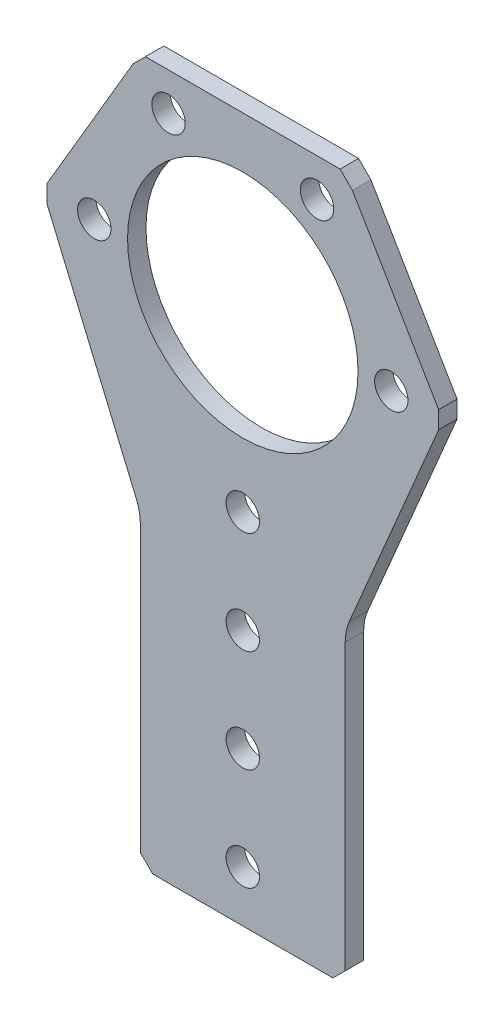
from build123d import *

# Parameters (mm, degrees)
SKETCH1_R           = 2.0701
SKETCH1_R_2         = 14.2875
BOSS_EXTRUDE1_DEPTH = 2.286


with BuildPart() as part:
    # Sketch1 → Boss-Extrude1 (new body)
    with BuildSketch(Plane.XY.offset(2.286)):
        with BuildLine():
            Line((-24.282138093, -1.253612903), (-13.20363246, -27.386969147))
            ThreePointArc((-13.20363246, -27.386969147), (-12.827181753, -28.600844397), (-12.7, -29.865373188))
            Line((-12.7, -29.865373188), (-12.7, -65.148356459))
            Line((-12.7, -65.148356459), (-11.173356459, -66.675))
            Line((-11.173356459, -66.675), (11.173356459, -66.675))
            Line((11.173356459, -66.675), (12.7, -65.148356459))
            Line((12.7, -65.148356459), (12.7, -29.865373188))
            ThreePointArc((12.7, -29.865373188), (12.827181753, -28.600844397), (13.20363246, -27.386969147))
            Line((13.20363246, -27.386969147), (24.282138093, -1.253612903))
            Line((24.282138093, -1.253612903), (24.282138093, 0.905387097))
            Line((24.282138093, 0.905387097), (13.596092395, 19.110856459))
            Line((13.596092395, 19.110856459), (12.069448854, 20.6375))
            Line((12.069448854, 20.6375), (-12.069448854, 20.6375))
            Line((-12.069448854, 20.6375), (-13.596092395, 19.110856459))
            Line((-13.596092395, 19.110856459), (-24.282138093, 0.905387097))
            Line((-24.282138093, 0.905387097), (-24.282138093, -1.253612903))
        make_face()
        with Locations((-9.2075, 15.947857811)):
            Circle(SKETCH1_R, mode=Mode.SUBTRACT)
        with Locations((-18.415, 0)):
            Circle(SKETCH1_R, mode=Mode.SUBTRACT)
        with Locations((0, -47.625)):
            Circle(SKETCH1_R, mode=Mode.SUBTRACT)
        with Locations((0, -22.225)):
            Circle(SKETCH1_R, mode=Mode.SUBTRACT)
        Circle(SKETCH1_R_2, mode=Mode.SUBTRACT)
        with Locations((0, -34.925)):
            Circle(SKETCH1_R, mode=Mode.SUBTRACT)
        with Locations((0, -60.325)):
            Circle(SKETCH1_R, mode=Mode.SUBTRACT)
        with Locations((18.415, 0)):
            Circle(SKETCH1_R, mode=Mode.SUBTRACT)
        with Locations((9.2075, 15.947857811)):
            Circle(SKETCH1_R, mode=Mode.SUBTRACT)
    extrude(amount=-BOSS_EXTRUDE1_DEPTH)


solid = part.part
